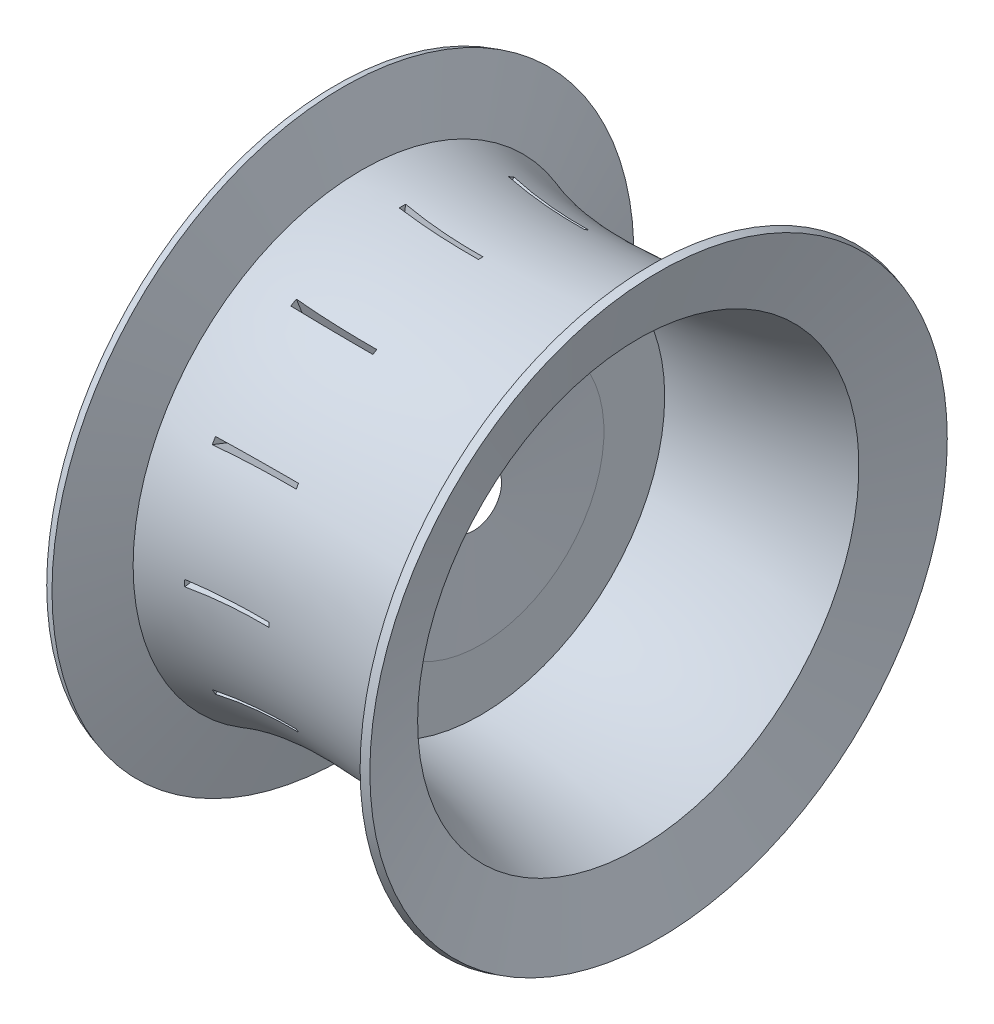
from build123d import *

# Parameters (mm, degrees)
CUT_EXTRUDE1_DEPTH = 25.4


with BuildPart() as part:
    # Sketch1 → Revolve1 (revolve)
    with BuildSketch(Plane.XY):
        with BuildLine():
            Line((-50, 94.429578452), (-43.950074951, 74.146502495))
            add(Edge.make_bspline(
                [(-43.950074951, 74.146502495), (-30.324787154, 69.527502201), (-7.935332232, 64.635999311), (43.950074951, 74.146502495)],
                knots=[0, 0, 0, 0, 1, 1, 1, 1], degree=3))
            Line((43.950074951, 74.146502495), (50, 94.429578452))
            Line((50, 94.429578452), (52.434031632, 93.703568799))
            Line((52.434031632, 93.703568799), (45.843039456, 71.606502495))
            add(Edge.make_bspline(
                [(-5.291699224, 59.717748904), (20.861844129, 60.268983178), (45.843039456, 71.606502495)],
                knots=[0.463836412, 0.463836412, 0.463836412, 1, 1, 1], degree=2))
            Line((-5.291699224, 59.717748904), (-5.291699224, 40))
            Line((-5.291699224, 40), (-7.524484902, 9))
            Line((-7.524484902, 9), (-7.524484902, 59.790811734))
            add(Edge.make_bspline(
                [(-45.843039456, 71.606502495), (-27.071768847, 58.162400144), (-31.463870641, 60.513484529), (-7.524484902, 59.790811734)],
                knots=[0, 0, 0, 0, 0.44581559, 0.44581559, 0.44581559, 0.44581559], degree=3))
            Line((-45.843039456, 71.606502495), (-52.434031632, 93.703568799))
            Line((-52.434031632, 93.703568799), (-50, 94.429578452))
        make_face()
    revolve(axis=Axis((-165.294689037, 0, 0), (1, 0, 0)))

    # Sketch2 → Cut-Extrude1 (cut)
    with BuildSketch(Plane(origin=(-5.291699224, 0, 0), x_dir=(0, 0, -1), z_dir=(1, 0, 0))):
        Polygon((0, 63.958336037), (-9.083437699, 122.299155441), (9.083437699, 122.299155441), align=None)
        Polygon((31.979168019, 55.389543792), (53.283089919, 110.455894323), (69.016065522, 101.372456624), align=None)
        Polygon((55.389543792, 31.979168019), (101.372456624, 69.016065522), (110.455894323, 53.283089919), align=None)
        Polygon((63.958336037, 0), (122.299155441, 9.083437699), (122.299155441, -9.083437699), align=None)
        Polygon((55.389543792, -31.979168019), (110.455894323, -53.283089919), (101.372456624, -69.016065522), align=None)
        Polygon((31.979168019, -55.389543792), (69.016065522, -101.372456624), (53.283089919, -110.455894323), align=None)
        Polygon((0, -63.958336037), (9.083437699, -122.299155441), (-9.083437699, -122.299155441), align=None)
        Polygon((-31.979168019, -55.389543792), (-53.283089919, -110.455894323), (-69.016065522, -101.372456624), align=None)
        Polygon((-55.389543792, -31.979168019), (-101.372456624, -69.016065522), (-110.455894323, -53.283089919), align=None)
        Polygon((-63.958336037, 0), (-122.299155441, -9.083437699), (-122.299155441, 9.083437699), align=None)
        Polygon((-55.389543792, 31.979168019), (-110.455894323, 53.283089919), (-101.372456624, 69.016065522), align=None)
        Polygon((-31.979168019, 55.389543792), (-69.016065522, 101.372456624), (-53.283089919, 110.455894323), align=None)
    extrude(amount=-CUT_EXTRUDE1_DEPTH, mode=Mode.SUBTRACT)


solid = part.part
